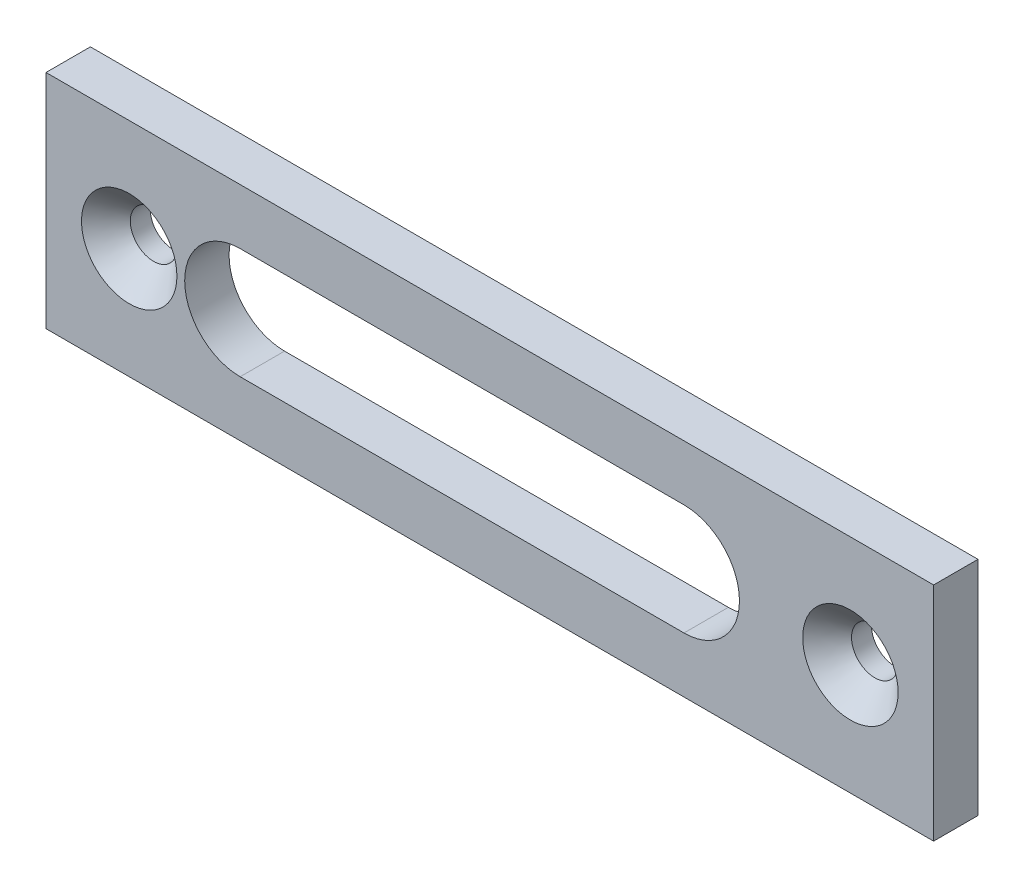
from build123d import *

# Parameters (mm, degrees)
ESQUISSE1_W      = 80
ESQUISSE1_H      = 20
ESQUISSE1_R      = 2.1
EXTRUSION1_DEPTH = 4
CHANFREIN1_SIZE  = 2.2


with BuildPart() as part:
    # Esquisse1 → Extrusion1 (new body)
    with BuildSketch(Plane.XY):
        Rectangle(ESQUISSE1_W, ESQUISSE1_H)
        with Locations((-32.5, 0)):
            Circle(ESQUISSE1_R, mode=Mode.SUBTRACT)
        with Locations((32.5, 0)):
            Circle(ESQUISSE1_R, mode=Mode.SUBTRACT)
        with BuildLine():
            Line((-22.5, 5), (17.5, 5))
            ThreePointArc((17.5, 5), (22.5, 0), (17.5, -5))
            Line((17.5, -5), (-22.5, -5))
            ThreePointArc((-22.5, -5), (-27.5, 0), (-22.5, 5))
        make_face(mode=Mode.SUBTRACT)
    extrude(amount=EXTRUSION1_DEPTH)

    # Chanfrein1
    chanfrein1_edges = [part.edges().sort_by_distance(p)[0] for p in [
        (-34.6, 0, 4),
        (30.4, 0, 4),
    ]]
    chamfer(chanfrein1_edges, length=CHANFREIN1_SIZE)


solid = part.part
